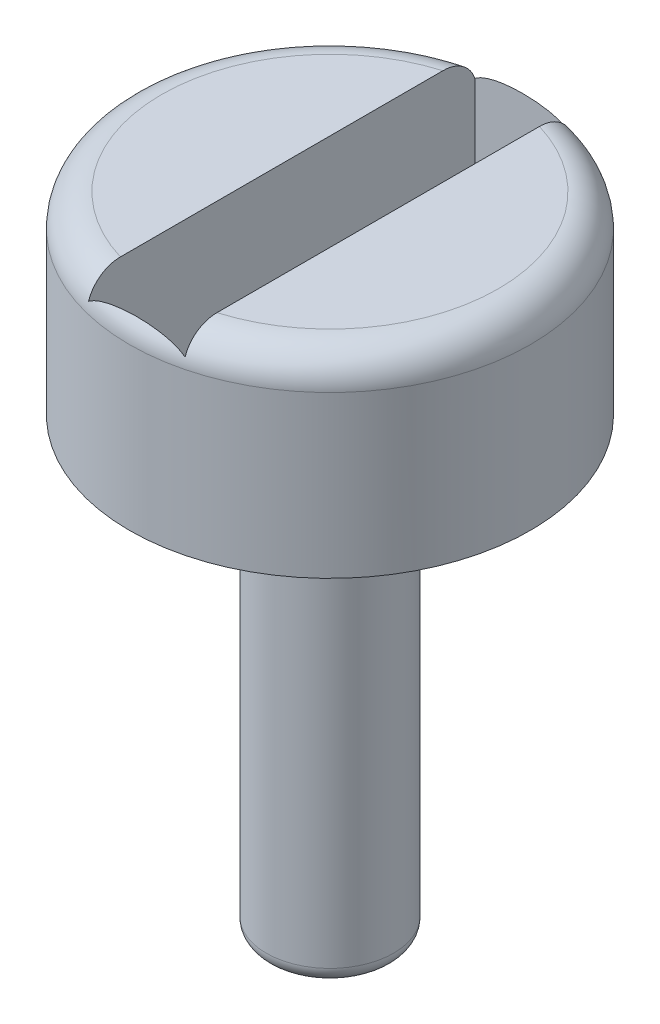
from build123d import *

# Parameters (mm, degrees)
FILLET1_R          = 0.5
FILLET2_R          = 0.25
CUT_EXTRUDE1_DEPTH = 2


with BuildPart() as part:
    # Sketch2 → Revolve1 (revolve)
    with BuildSketch(Plane.XY):
        Polygon((0, 0), (3.115, 0), (3.115, -3), (0.99, -3), (0.99, -10), (0, -10), align=None)
    revolve(axis=Axis((0, 0, 0), (0, -1, 0)))

    # Fillet1
    fillet1_edges = [part.edges().sort_by_distance(p)[0] for p in [
        (-3.115, 0, 0),
    ]]
    fillet(fillet1_edges, radius=FILLET1_R)

    # Fillet2
    fillet2_edges = [part.edges().sort_by_distance(p)[0] for p in [
        (-0.99, -10, 0),
    ]]
    fillet(fillet2_edges, radius=FILLET2_R)

    # Sketch4 → Cut-Extrude1 (cut)
    with BuildSketch(Plane(origin=(0, 0, 0), x_dir=(1, 0, 0), z_dir=(0, 1, 0))):
        Polygon((0.75, -3), (0.75, 0.051459753), (0.75, 3), (-0.75, 3), (-0.75, -3), align=None)
    extrude(amount=-CUT_EXTRUDE1_DEPTH, mode=Mode.SUBTRACT)


solid = part.part
